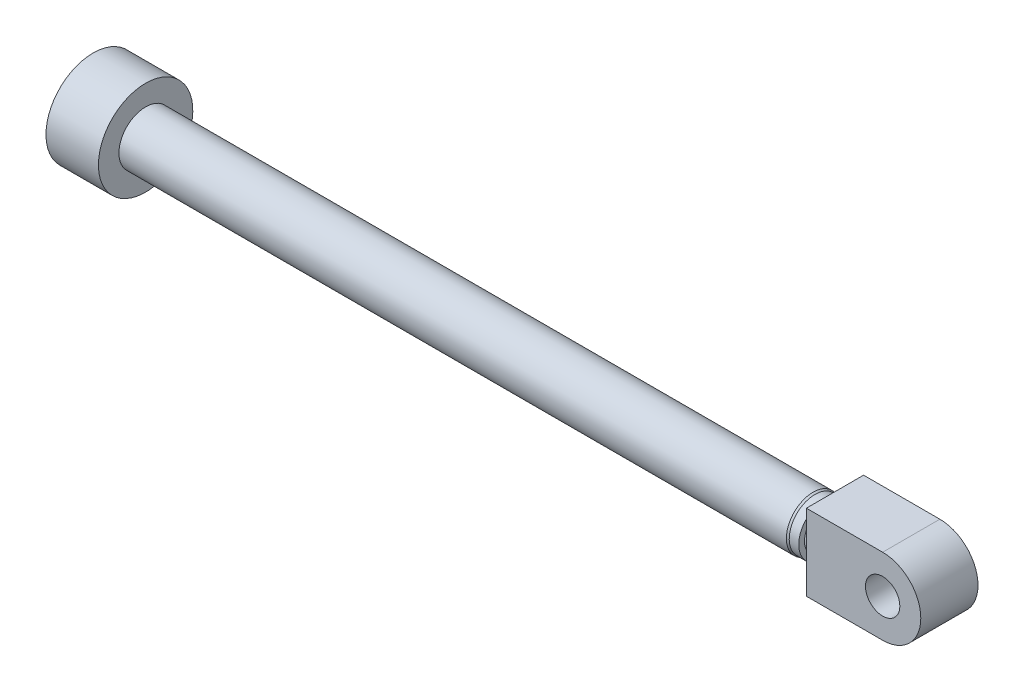
from build123d import *

# Parameters (mm, degrees)
ESBO_O2_R                     = 77.954078429
ESBO_O2_R_2                   = 21.25
RESSALTO_EXTRUS_O1_DEPTH      = 75
RESSALTO_EXTRUS_O1_DEPTH_BACK = 45
ESBO_O4_R                     = 21.25
RESSALTO_EXTRUS_O3_DEPTH      = 74
ESBO_O5_W                     = 132.299972888
ESBO_O5_H                     = 165.7142615
ESBO_O5_R                     = 18
CORTE_EXTRUS_O1_DEPTH         = 78.954078429
CORTE_EXTRUS_O1_DEPTH_BACK    = 78.954078429
ESBO_O6_W                     = 80
ESBO_O6_H                     = 36.909179817
CORTE_EXTRUS_O2_DEPTH         = 10.5
CORTE_EXTRUS_O2_DEPTH_BACK    = 90.5
ESBO_O7_R                     = 21
RESSALTO_EXTRUS_O4_DEPTH      = 20


with BuildPart() as part:
    # Esboço1 → Revolução1 (revolve)
    with BuildSketch(Plane.XY):
        Polygon((0, 0), (0, 49.5), (55, 49.5), (55, 28), (755, 28), (757, 27), (767, 27), (767, 21), (823, 21), (823, 0), align=None)
    revolve(axis=Axis((823, 0, 0), (-1, 0, 0)))


with BuildPart() as body_2:
    # Esboço2 → Ressalto-extrusão1 (new body, two sides)
    with BuildSketch(Plane(origin=(823, 0, 0), x_dir=(0, 0, -1), z_dir=(1, 0, 0))) as ressalto_extrus_o1_sk:
        Circle(ESBO_O2_R)
        Circle(ESBO_O2_R_2, mode=Mode.SUBTRACT)
    extrude(amount=RESSALTO_EXTRUS_O1_DEPTH)
    extrude(ressalto_extrus_o1_sk.sketch, amount=-RESSALTO_EXTRUS_O1_DEPTH_BACK)

    # Esboço4 → Ressalto-extrusão3 (add)
    with BuildSketch(Plane(origin=(898, 0, 0), x_dir=(0, 0, -1), z_dir=(1, 0, 0))):
        Circle(ESBO_O4_R)
    extrude(amount=-RESSALTO_EXTRUS_O3_DEPTH)


with BuildPart() as corte_extrus_o1_tool:
    # Esboço5 → Corte-extrusão1 (new body, two sides)
    with BuildSketch(Plane.XY) as corte_extrus_o1_sk:
        with Locations((838, 0)):
            Rectangle(ESBO_O5_W, ESBO_O5_H)
        with BuildLine():
            Line((778, 40), (858, 40))
            ThreePointArc((858, 40), (886.284271247, 28.284271247), (898, 0))
            ThreePointArc((898, 0), (886.284271247, -28.284271247), (858, -40))
            Line((858, -40), (778, -40))
            Line((778, -40), (778, 40))
        make_face(mode=Mode.SUBTRACT)
        with Locations((858, 0)):
            Circle(ESBO_O5_R)
    extrude(amount=CORTE_EXTRUS_O1_DEPTH)
    extrude(corte_extrus_o1_sk.sketch, amount=-CORTE_EXTRUS_O1_DEPTH_BACK)


with BuildPart() as part_1:
    add(part.part)

    # Corte-extrusão1: cut by corte_extrus_o1_tool
    add(corte_extrus_o1_tool.part, mode=Mode.SUBTRACT)

    # Esboço7 → Ressalto-extrusão4 (add)
    with BuildSketch(Plane(origin=(771.850013556, 0, 0), x_dir=(0, 0, -1), z_dir=(1, 0, 0))):
        Circle(ESBO_O7_R)
    extrude(amount=RESSALTO_EXTRUS_O4_DEPTH)


with BuildPart() as body_2_1:
    add(body_2.part)

    # Corte-extrusão1: cut by corte_extrus_o1_tool
    add(corte_extrus_o1_tool.part, mode=Mode.SUBTRACT)

    # Esboço6 → Corte-extrusão2 (cut, two sides)
    with BuildSketch(Plane(origin=(0, 40, 0), x_dir=(1, 0, 0), z_dir=(0, 1, 0))) as corte_extrus_o2_sk:
        Polygon((773.594508965, 104.877127038), (773.594508965, 30), (778, 30), (778, 66.909179817), (858, 66.909179817), (858, 30), (942.405491035, 30), (942.405491035, 104.877127038), align=None)
        with Locations((818, 48.454589909)):
            Rectangle(ESBO_O6_W, ESBO_O6_H)
        Polygon((778, -30), (773.594508965, -30), (773.594508965, -104.877127038), (942.405491035, -104.877127038), (942.405491035, -30), (858, -30), (858, -66.909179817), (778, -66.909179817), align=None)
        with Locations((818, -48.454589909)):
            Rectangle(ESBO_O6_W, ESBO_O6_H)
    extrude(amount=CORTE_EXTRUS_O2_DEPTH, mode=Mode.SUBTRACT)
    extrude(corte_extrus_o2_sk.sketch, amount=-CORTE_EXTRUS_O2_DEPTH_BACK, mode=Mode.SUBTRACT)


solid = Compound([part_1.part, body_2_1.part])
